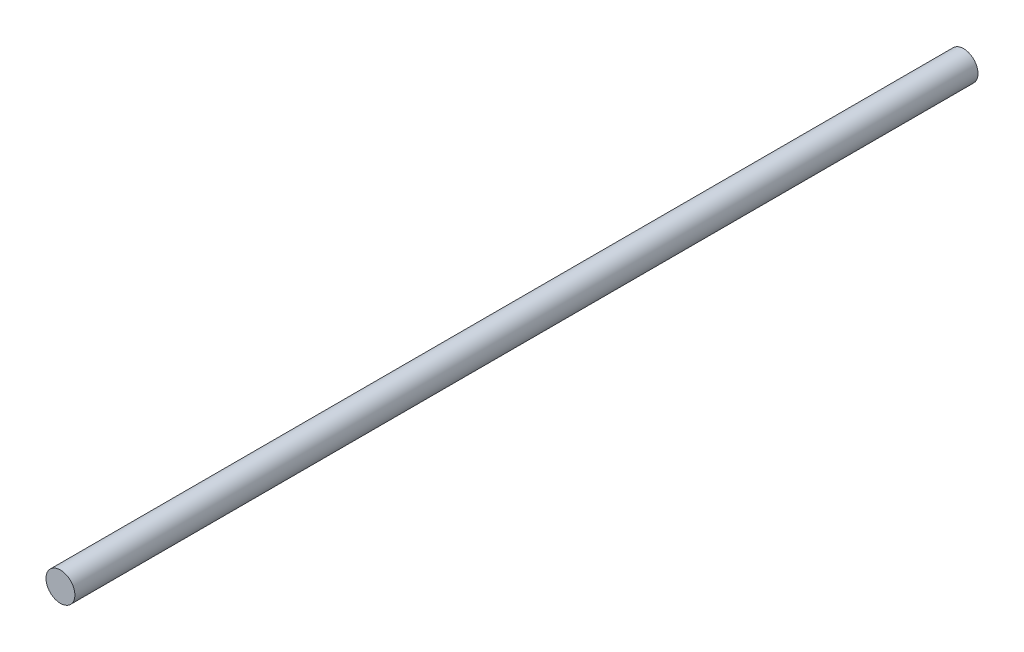
from build123d import *

# Parameters (mm, degrees)
SKETCH1_R           = 1.016
BOSS_EXTRUDE1_DEPTH = 63.5


with BuildPart() as part:
    # Sketch1 → Boss-Extrude1 (new body)
    with BuildSketch(Plane.XY):
        Circle(SKETCH1_R)
    extrude(amount=-BOSS_EXTRUDE1_DEPTH)


solid = part.part
